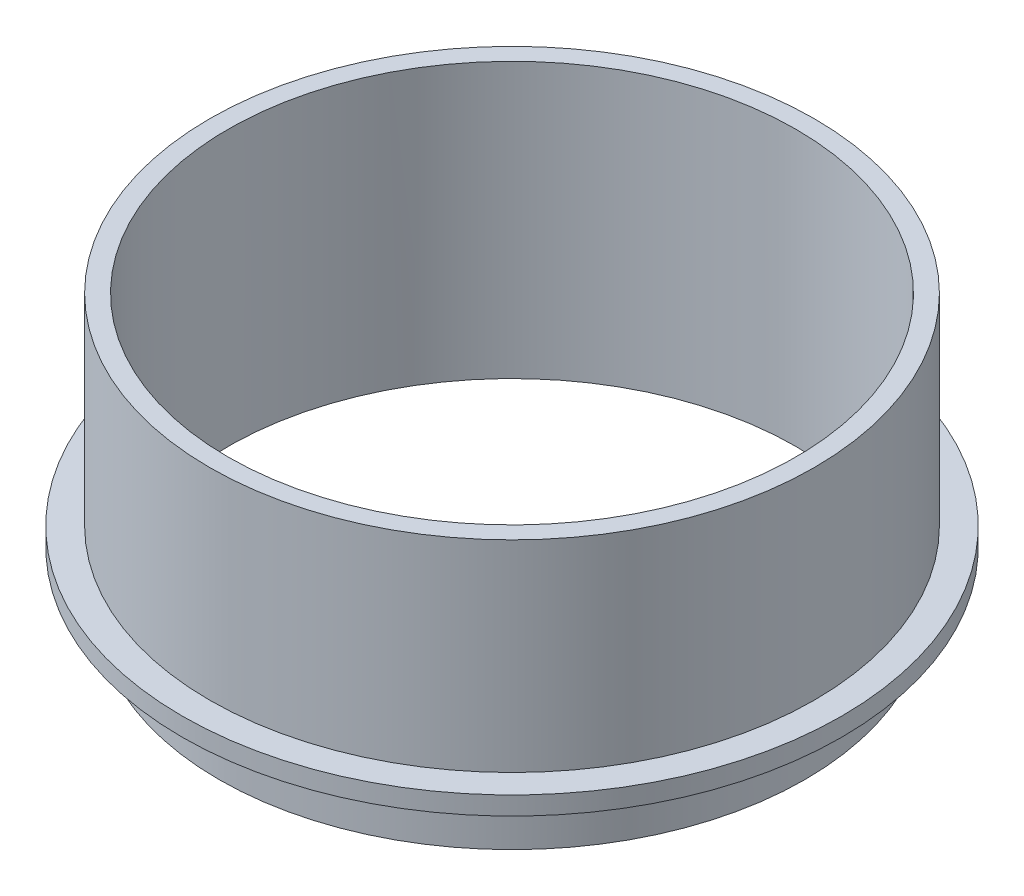
from build123d import *

# Parameters (mm, degrees)
SKETCH1_R           = 52.3875
SKETCH1_R_2         = 49.2125
BOSS_EXTRUDE1_DEPTH = 38.1
SKETCH2_R           = 50.8
SKETCH2_R_2         = 49.2125
BOSS_EXTRUDE2_DEPTH = 9.525
SKETCH3_R           = 57.15
SKETCH3_R_2         = 52.3875
BOSS_EXTRUDE3_DEPTH = 3.175


with BuildPart() as part:
    # Sketch1 → Boss-Extrude1 (new body)
    with BuildSketch(Plane(origin=(0, 0, 0), x_dir=(1, 0, 0), z_dir=(0, 1, 0))):
        Circle(SKETCH1_R)
        Circle(SKETCH1_R_2, mode=Mode.SUBTRACT)
    extrude(amount=BOSS_EXTRUDE1_DEPTH)

    # Sketch2 → Boss-Extrude2 (add)
    with BuildSketch(Plane.XZ):
        Circle(SKETCH2_R)
        Circle(SKETCH2_R_2, mode=Mode.SUBTRACT)
    extrude(amount=BOSS_EXTRUDE2_DEPTH)

    # Sketch3 → Boss-Extrude3 (add)
    with BuildSketch(Plane.XZ):
        Circle(SKETCH3_R)
        Circle(SKETCH3_R_2, mode=Mode.SUBTRACT)
    extrude(amount=-BOSS_EXTRUDE3_DEPTH)


solid = part.part
